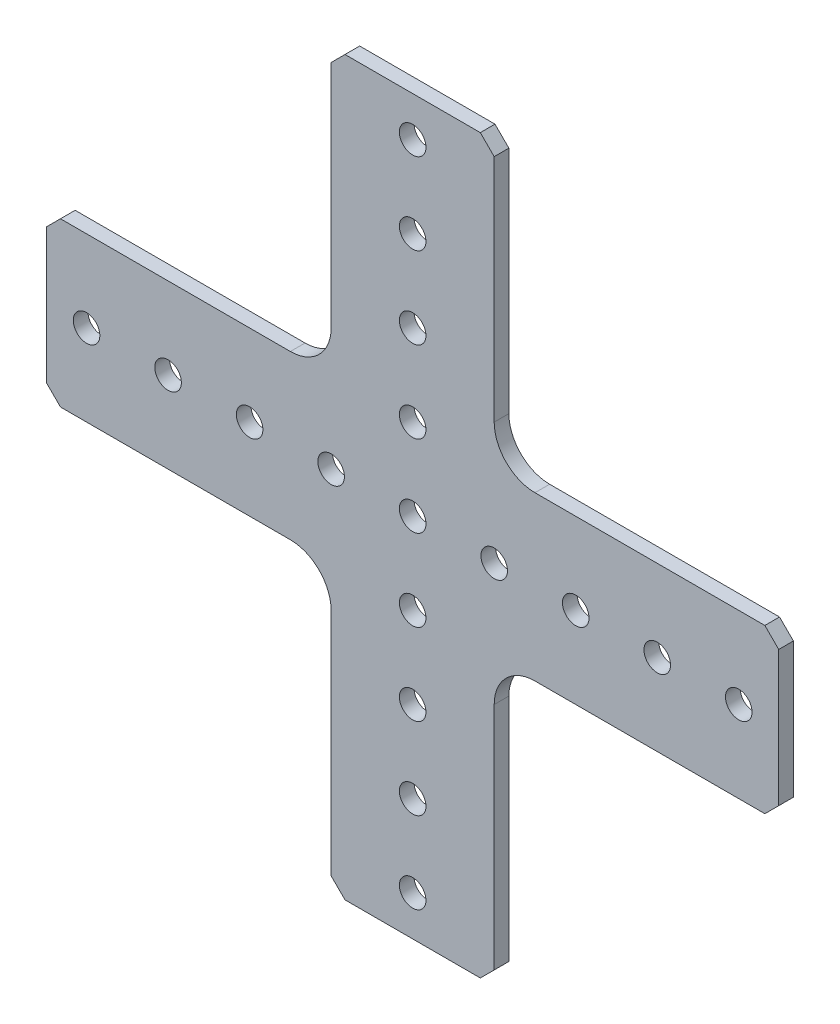
from build123d import *

# Parameters (mm, degrees)
SKETCH1_R           = 2.0701
BOSS_EXTRUDE1_DEPTH = 2.286


with BuildPart() as part:
    # Sketch1 → Boss-Extrude1 (new body)
    with BuildSketch(Plane.XY.offset(2.286)):
        with BuildLine():
            Line((57.023, 10.541), (54.864, 12.7))
            Line((54.864, 12.7), (19.05, 12.7))
            ThreePointArc((19.05, 12.7), (14.559871939, 14.559871939), (12.7, 19.05))
            Line((12.7, 19.05), (12.7, 54.864))
            Line((12.7, 54.864), (10.541, 57.023))
            Line((10.541, 57.023), (-10.541, 57.023))
            Line((-10.541, 57.023), (-12.7, 54.864))
            Line((-12.7, 54.864), (-12.7, 19.05))
            ThreePointArc((-12.7, 19.05), (-14.559871939, 14.559871939), (-19.05, 12.7))
            Line((-19.05, 12.7), (-54.864, 12.7))
            Line((-54.864, 12.7), (-57.023, 10.541))
            Line((-57.023, 10.541), (-57.023, -10.541))
            Line((-57.023, -10.541), (-54.864, -12.7))
            Line((-54.864, -12.7), (-19.05, -12.7))
            ThreePointArc((-19.05, -12.7), (-14.559871939, -14.559871939), (-12.7, -19.05))
            Line((-12.7, -19.05), (-12.7, -54.864))
            Line((-12.7, -54.864), (-10.541, -57.023))
            Line((-10.541, -57.023), (10.541, -57.023))
            Line((10.541, -57.023), (12.7, -54.864))
            Line((12.7, -54.864), (12.7, -19.05))
            ThreePointArc((12.7, -19.05), (14.559871939, -14.559871939), (19.05, -12.7))
            Line((19.05, -12.7), (54.864, -12.7))
            Line((54.864, -12.7), (57.023, -10.541))
            Line((57.023, -10.541), (57.023, 10.541))
        make_face()
        with Locations((0, 12.7)):
            Circle(SKETCH1_R, mode=Mode.SUBTRACT)
        with Locations((0, 38.1)):
            Circle(SKETCH1_R, mode=Mode.SUBTRACT)
        with Locations((-12.7, 0)):
            Circle(SKETCH1_R, mode=Mode.SUBTRACT)
        with Locations((-38.1, 0)):
            Circle(SKETCH1_R, mode=Mode.SUBTRACT)
        with Locations((50.8, 0)):
            Circle(SKETCH1_R, mode=Mode.SUBTRACT)
        with Locations((0, -38.1)):
            Circle(SKETCH1_R, mode=Mode.SUBTRACT)
        with Locations((0, -12.7)):
            Circle(SKETCH1_R, mode=Mode.SUBTRACT)
        with Locations((25.4, 0)):
            Circle(SKETCH1_R, mode=Mode.SUBTRACT)
        Circle(SKETCH1_R, mode=Mode.SUBTRACT)
        with Locations((12.7, 0)):
            Circle(SKETCH1_R, mode=Mode.SUBTRACT)
        with Locations((38.1, 0)):
            Circle(SKETCH1_R, mode=Mode.SUBTRACT)
        with Locations((0, -25.4)):
            Circle(SKETCH1_R, mode=Mode.SUBTRACT)
        with Locations((0, -50.8)):
            Circle(SKETCH1_R, mode=Mode.SUBTRACT)
        with Locations((-50.8, 0)):
            Circle(SKETCH1_R, mode=Mode.SUBTRACT)
        with Locations((-25.4, 0)):
            Circle(SKETCH1_R, mode=Mode.SUBTRACT)
        with Locations((0, 50.8)):
            Circle(SKETCH1_R, mode=Mode.SUBTRACT)
        with Locations((0, 25.4)):
            Circle(SKETCH1_R, mode=Mode.SUBTRACT)
    extrude(amount=-BOSS_EXTRUDE1_DEPTH)


solid = part.part
